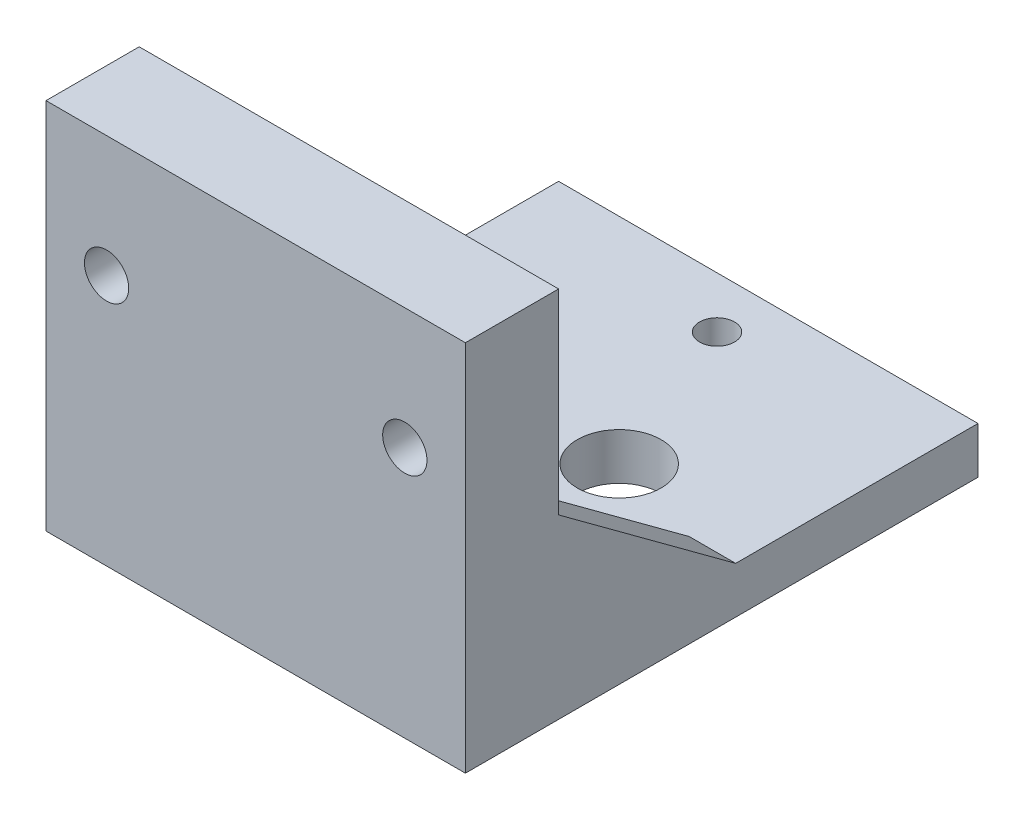
from build123d import *

# Parameters (mm, degrees)
SKETCH7_W               = 45
SKETCH7_H               = 45
SKETCH7_R               = 1.875
SKETCH7_R_2             = 14
SKETCH7_R_3             = 4.5
BOSS_EXTRUDE5_DEPTH     = 5
SKETCH7_3_W             = 45
SKETCH7_3_H             = 2
BOSS_EXTRUDE6_DEPTH     = 40
BOSS_EXTRUDE7_DEPTH     = 5
SKETCH7_4_W             = 45
SKETCH7_4_H             = 8
BOSS_EXTRUDE8_DEPTH     = 40
SKETCH10_R              = 2.375
CUT_EXTRUDE2_DEPTH      = 9
CUT_EXTRUDE2_DEPTH_BACK = 5


with BuildPart() as part:
    # Sketch7 → Boss-Extrude5 (new body)
    with BuildSketch(Plane(origin=(0, 0, 0), x_dir=(1, 0, 0), z_dir=(0, 1, 0))):
        with Locations((5.756289545, -118.050969126)):
            Rectangle(SKETCH7_W, SKETCH7_H)
        with Locations((5.756289545, -136.050969126)):
            Circle(SKETCH7_R, mode=Mode.SUBTRACT)
        with Locations((5.362034713, -118.985312035)):
            Circle(SKETCH7_R_2, mode=Mode.SUBTRACT)
        with Locations((5.756289545, -101.050969126)):
            Circle(SKETCH7_R, mode=Mode.SUBTRACT)
        with Locations((5.362034713, -118.985312035)):
            Circle(SKETCH7_R_2)
        with Locations((12.756289545, -118.550969126)):
            Circle(SKETCH7_R_3, mode=Mode.SUBTRACT)
    extrude(amount=BOSS_EXTRUDE5_DEPTH)

    # Sketch7_3 → Boss-Extrude6 (add)
    with BuildSketch(Plane(origin=(0, 0, 0), x_dir=(1, 0, 0), z_dir=(0, 1, 0))):
        with Locations((5.756289545, -141.550969126)):
            Rectangle(SKETCH7_3_W, SKETCH7_3_H)
    extrude(amount=BOSS_EXTRUDE6_DEPTH)

    # Sketch8 → Boss-Extrude7 (add)
    with BuildSketch(Plane.ZY.offset(16.743710455)):
        Polygon((140.550969126, 11), (140.550969126, 5), (121.550969126, 5), (140.550969126, 19), align=None)
    boss_extrude7 = extrude(amount=-BOSS_EXTRUDE7_DEPTH)

    # Mirror2: Boss-Extrude7 across plane
    add(boss_extrude7.mirror(Plane.ZY.offset(-5.756289545)))

    # Sketch7_4 → Boss-Extrude8 (add)
    with BuildSketch(Plane(origin=(0, 0, 0), x_dir=(1, 0, 0), z_dir=(0, 1, 0))):
        with Locations((5.756289545, -146.550969126)):
            Rectangle(SKETCH7_4_W, SKETCH7_4_H)
    extrude(amount=BOSS_EXTRUDE8_DEPTH)

    # Sketch10 → Cut-Extrude2 (cut, two sides)
    with BuildSketch(Plane.XY.offset(142.550969126)) as cut_extrude2_sk:
        with Locations((21.756289545, 27)):
            Circle(SKETCH10_R)
        with Locations((-10.243710455, 27)):
            Circle(SKETCH10_R)
    extrude(amount=CUT_EXTRUDE2_DEPTH, mode=Mode.SUBTRACT)
    extrude(cut_extrude2_sk.sketch, amount=-CUT_EXTRUDE2_DEPTH_BACK, mode=Mode.SUBTRACT)


solid = part.part
